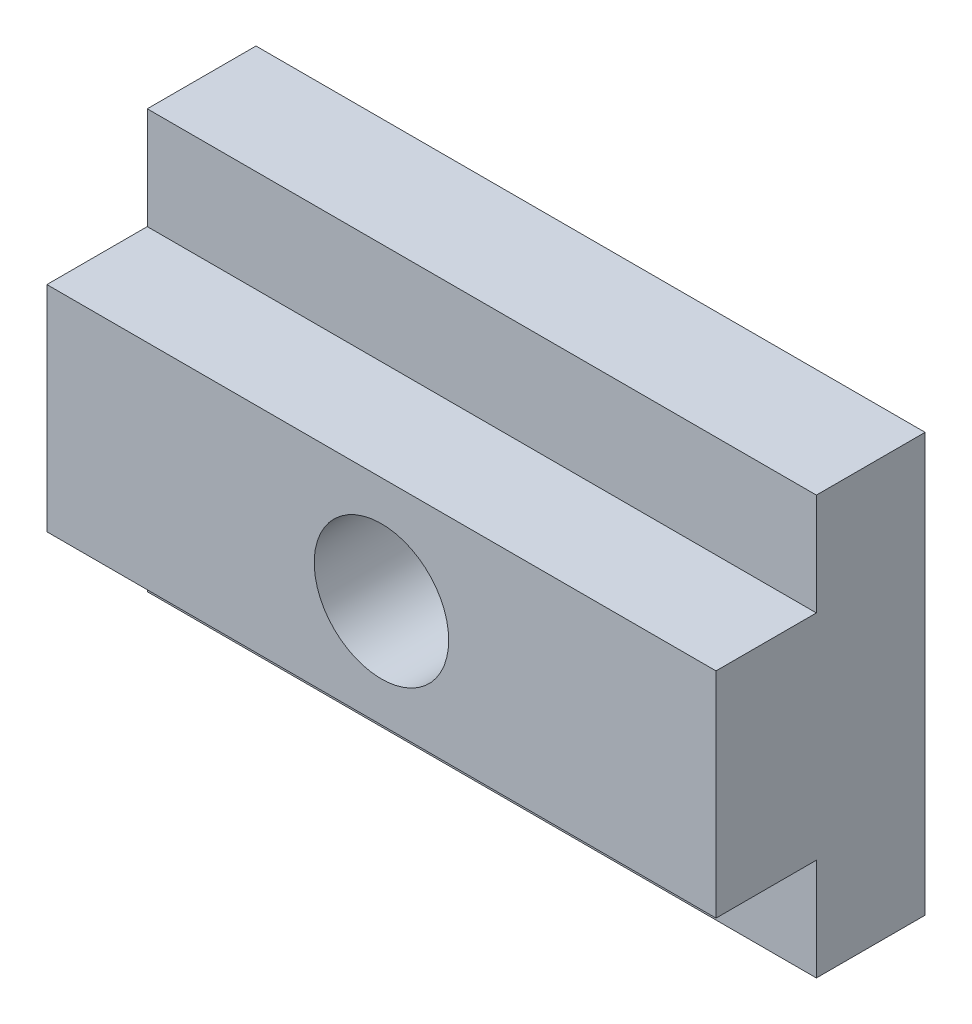
from build123d import *

# Parameters (mm, degrees)
SKETCH1_W                   = 25.4
SKETCH1_H                   = 15.875
BOSS_EXTRUDE1_DEPTH         = 7.9375
CUT_EXTRUDE1_REACH          = 27.4
SKETCH2_W                   = 3.81
SKETCH2_H                   = 3.8735
F_1_4_20_TAPPED_HOLE1_D     = 5.1054
F_1_4_20_TAPPED_HOLE1_DEPTH = 16.51
F_1_4_20_TAPPED_HOLE1_TIP   = 1.533816902


with BuildPart() as part:
    # Sketch1 → Boss-Extrude1 (new body)
    with BuildSketch(Plane.XY):
        Rectangle(SKETCH1_W, SKETCH1_H)
    extrude(amount=BOSS_EXTRUDE1_DEPTH)

    # Sketch2 → Cut-Extrude1 (cut, up to next)
    with BuildSketch(Plane(origin=(12.7, 0, 0), x_dir=(0, 0, -1), z_dir=(1, 0, 0)), mode=Mode.PRIVATE) as cut_extrude1_sk1:
        with Locations((-6.0325, 6.00075)):
            Rectangle(SKETCH2_W, SKETCH2_H)
    cut_extrude1_tool1 = extrude(cut_extrude1_sk1.sketch, amount=-CUT_EXTRUDE1_REACH, mode=Mode.PRIVATE) & part.part
    add(cut_extrude1_tool1.solids().sort_by_distance((12.7, 6.00075, 6.0325))[0], mode=Mode.SUBTRACT)
    # Sketch2 → Cut-Extrude1 (cut, up to next)
    with BuildSketch(Plane(origin=(12.7, 0, 0), x_dir=(0, 0, -1), z_dir=(1, 0, 0)), mode=Mode.PRIVATE) as cut_extrude1_sk2:
        with Locations((-6.0325, -6.00075)):
            Rectangle(SKETCH2_W, SKETCH2_H)
    cut_extrude1_tool2 = extrude(cut_extrude1_sk2.sketch, amount=-CUT_EXTRUDE1_REACH, mode=Mode.PRIVATE) & part.part
    add(cut_extrude1_tool2.solids().sort_by_distance((12.7, -6.00075, 6.0325))[0], mode=Mode.SUBTRACT)

    # 1/4-20 Tapped Hole1
    with Locations(Plane.XY.offset(7.9375)):
        with Locations((0, 0)):
            Hole(F_1_4_20_TAPPED_HOLE1_D / 2, depth=F_1_4_20_TAPPED_HOLE1_DEPTH)
            with Locations((0, 0, -(F_1_4_20_TAPPED_HOLE1_DEPTH + F_1_4_20_TAPPED_HOLE1_TIP / 2))):  # 118° drill point
                Cone(0, F_1_4_20_TAPPED_HOLE1_D / 2, F_1_4_20_TAPPED_HOLE1_TIP, mode=Mode.SUBTRACT)


solid = part.part
